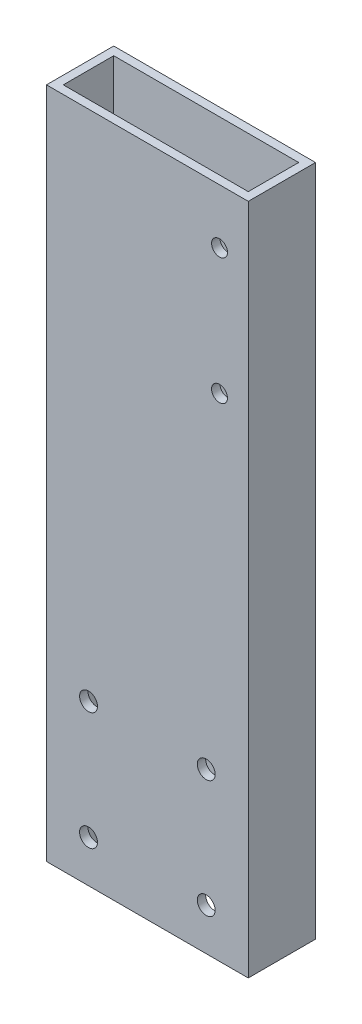
from build123d import *

# Parameters (mm, degrees)
SKETCH1_W           = 76.2
SKETCH1_H           = 25.4
SKETCH1_W_2         = 69.85
SKETCH1_H_2         = 19.05
BOSS_EXTRUDE1_DEPTH = 254
SKETCH2_R           = 3.3782
CUT_EXTRUDE1_DEPTH  = 26.4
SKETCH3_R           = 3
CUT_EXTRUDE2_DEPTH  = 26.4


with BuildPart() as part:
    # Sketch1 → Boss-Extrude1 (new body)
    with BuildSketch(Plane(origin=(0, 0, 0), x_dir=(1, 0, 0), z_dir=(0, 1, 0))):
        with Locations((38.1, 12.7)):
            Rectangle(SKETCH1_W, SKETCH1_H)
        with Locations((38.1, 12.7)):
            Rectangle(SKETCH1_W_2, SKETCH1_H_2, mode=Mode.SUBTRACT)
    extrude(amount=BOSS_EXTRUDE1_DEPTH)

    # Sketch2 → Cut-Extrude1 (cut, through all)
    with BuildSketch(Plane(origin=(0, 0, -25.4), x_dir=(-1, 0, 0), z_dir=(0, 0, -1))):
        with Locations((-60.325, 15.875)):
            Circle(SKETCH2_R)
        with Locations((-15.875, 15.875)):
            Circle(SKETCH2_R)
        with Locations((-15.875, 60.325)):
            Circle(SKETCH2_R)
        with Locations((-60.325, 60.325)):
            Circle(SKETCH2_R)
    extrude(amount=-CUT_EXTRUDE1_DEPTH, mode=Mode.SUBTRACT)

    # Sketch3 → Cut-Extrude2 (cut, through all)
    with BuildSketch(Plane(origin=(0, 0, -25.4), x_dir=(-1, 0, 0), z_dir=(0, 0, -1))):
        with Locations((-65.347432125, 185.7375)):
            Circle(SKETCH3_R)
        with Locations((-65.347432125, 233.3625)):
            Circle(SKETCH3_R)
    extrude(amount=-CUT_EXTRUDE2_DEPTH, mode=Mode.SUBTRACT)


solid = part.part
